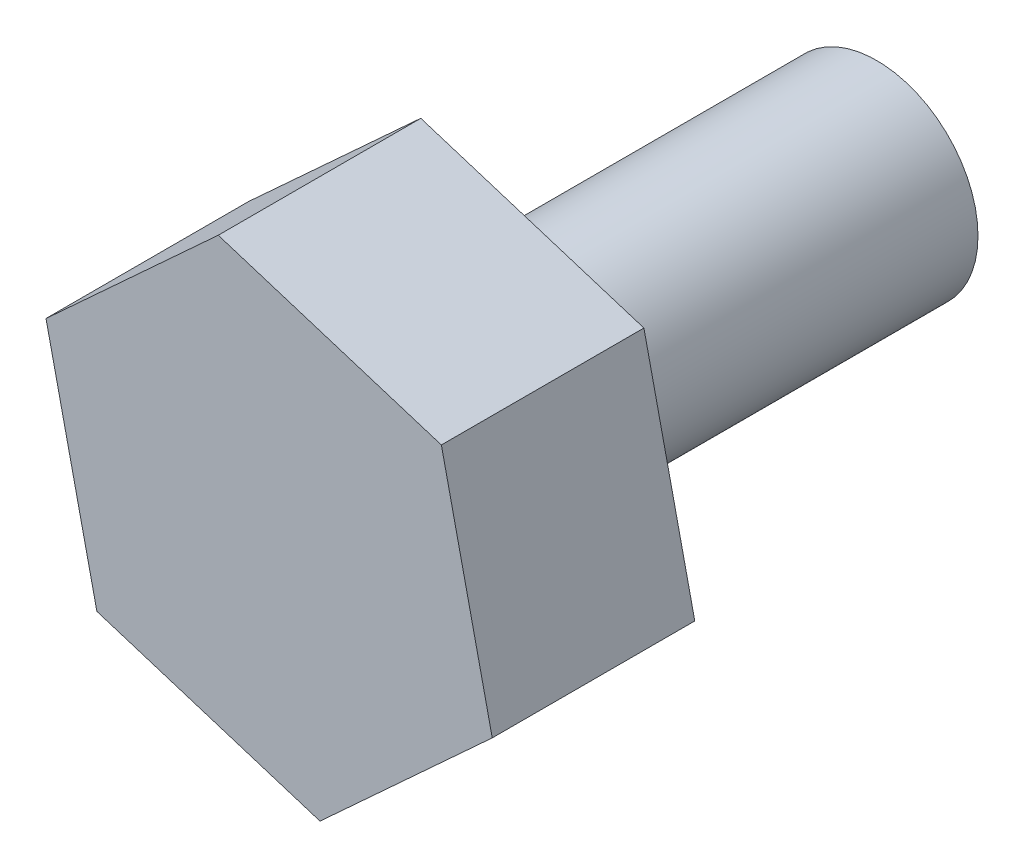
from build123d import *

# Parameters (mm, degrees)
EXTRUDE_1_DEPTH = 2
SKETCH_2_R      = 1
EXTRUDE_2_DEPTH = 4


with BuildPart() as part:
    # 草图1 → 凸台-拉伸1 (new body)
    with BuildSketch(Plane.XY):
        Polygon((0.502480901, -2.254073263), (2.203325159, -0.691875406), (1.700844257, 1.562197857), (-0.502480901, 2.254073263), (-2.203325159, 0.691875406), (-1.700844257, -1.562197857), align=None)
    extrude(amount=EXTRUDE_1_DEPTH)

    # 草图2 → 凸台-拉伸2 (add)
    with BuildSketch(Plane(origin=(0, 0, 0), x_dir=(-1, 0, 0), z_dir=(0, 0, -1))):
        Circle(SKETCH_2_R)
    extrude(amount=EXTRUDE_2_DEPTH)


solid = part.part
